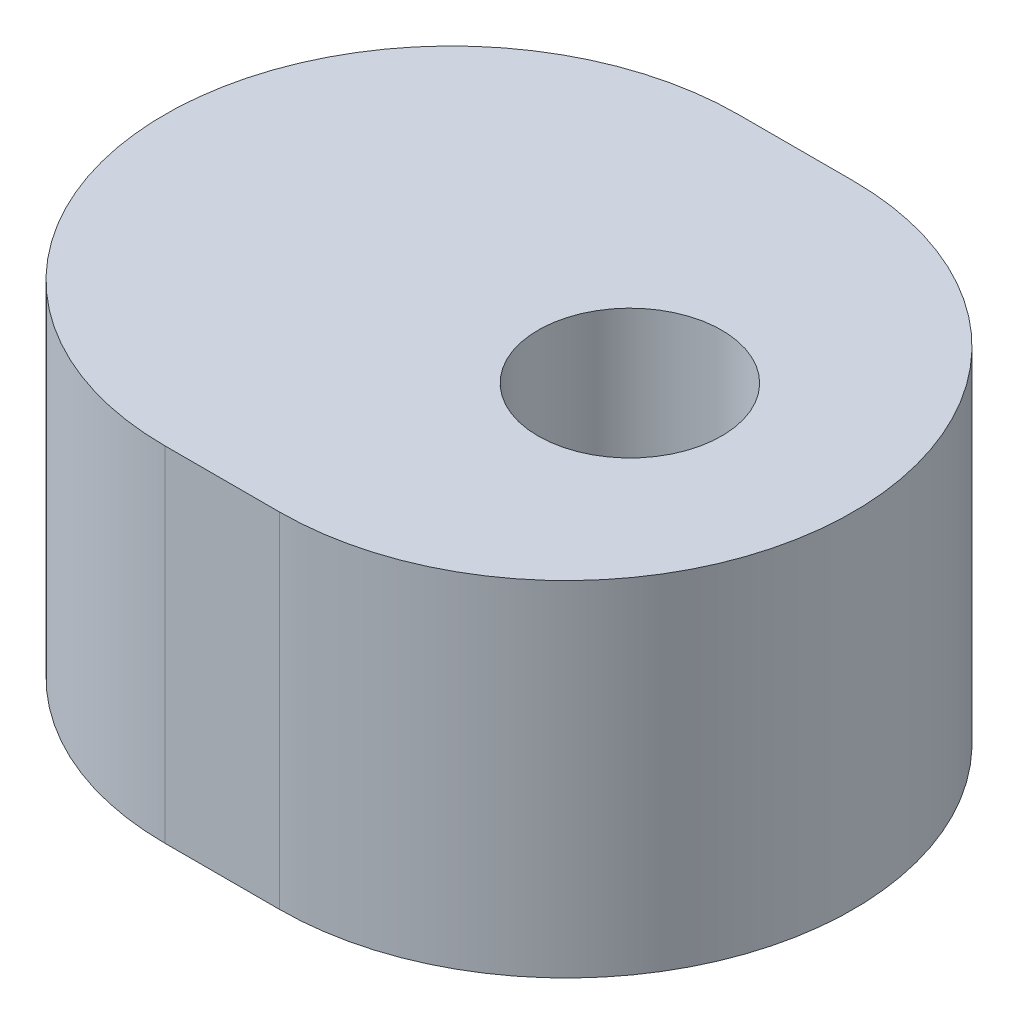
from build123d import *

# Parameters (mm, degrees)
ESBO_O1_R                = 1.6
RESSALTO_EXTRUS_O1_DEPTH = 6


with BuildPart() as part:
    # Esboço1 → Ressalto-extrusão1 (new body)
    with BuildSketch(Plane.XZ.offset(18)):
        with BuildLine():
            Line((-3.107348146, -5), (-1.107348146, -5))
            ThreePointArc((-1.107348146, -5), (3.892651854, 0), (-1.107348146, 5))
            Line((-1.107348146, 5), (-3.107348146, 5))
            ThreePointArc((-3.107348146, 5), (-8.107348146, 0), (-3.107348146, -5))
        make_face()
        Circle(ESBO_O1_R, mode=Mode.SUBTRACT)
    extrude(amount=-RESSALTO_EXTRUS_O1_DEPTH)


solid = part.part
